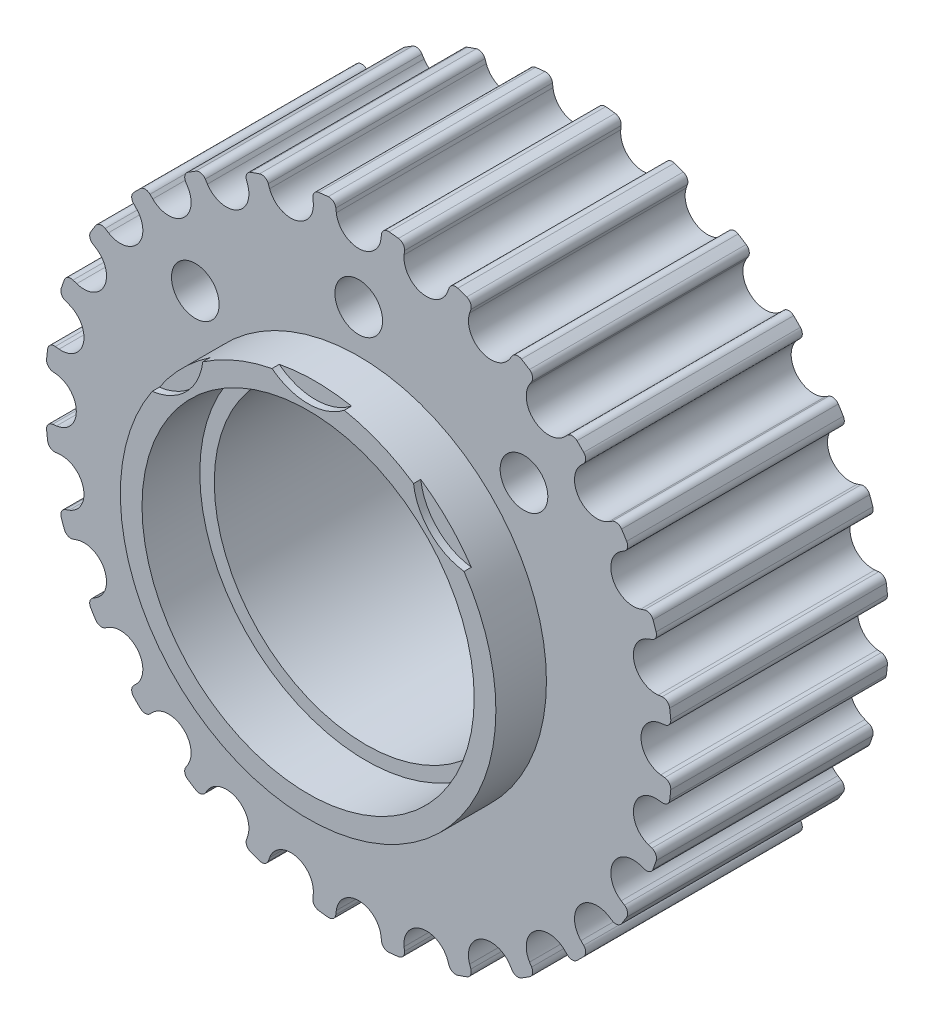
from build123d import *

# Parameters (mm, degrees)
SKETCH_2_R           = 10.5
EXTRUDE_1_DEPTH      = 15
SKETCH_12_R          = 13
SKETCH_12_R_2        = 11.5
EXTRUDE_2_DEPTH      = 3.5
EXTRUDE_2_DEPTH_BACK = 19.5
HOLE_WIZARD_M4_1_D   = 3.3
SKETCH_14_R          = 11.5
SKETCH_14_R_2        = 10.5
CUT_EXTRUDE_1_DEPTH  = 0.5
CUT_EXTRUDE_START    = 3.5
SKETCH_15_R          = 4.05
CUT_EXTRUDE_2_DEPTH  = 0.5
CUT_EXTRUDE_START_2  = -19.5
SKETCH_15_2_R        = 4.05
CUT_EXTRUDE_3_DEPTH  = 1.5
SKETCH_16_R          = 11.5
SKETCH_16_R_2        = 10.5
EXTRUDE_3_DEPTH      = 0.5


with BuildPart() as part:
    # 草图2 → 凸台-拉伸1 (new body)
    with BuildSketch(Plane.XY):
        with BuildLine():
            Line((1.331903556, 20.780403486), (1.298918642, 20.511762921))
            ThreePointArc((1.298918642, 20.511762921), (-0.249453355, 19.141879097), (-1.797825351, 20.511762921))
            Line((-1.797825351, 20.511762921), (-1.830810265, 20.780403486))
            ThreePointArc((-1.830810265, 20.780403486), (-2.006994407, 21.096415396), (-2.353762187, 21.19964565))
            ThreePointArc((-2.353762187, 21.19964565), (-2.679978202, 21.165383749), (-3.00563929, 21.12619674))
            ThreePointArc((-3.00563929, 21.12619674), (-3.320741986, 20.948391594), (-3.422189558, 20.601098103))
            Line((-3.422189558, 20.601098103), (-3.394569322, 20.331853084))
            ThreePointArc((-3.394569322, 20.331853084), (-4.599292572, 18.651769924), (-6.413671477, 19.642762718))
            Line((-6.413671477, 19.642762718), (-6.50560754, 19.897328069))
            ThreePointArc((-6.50560754, 19.897328069), (-6.747693643, 20.166212241), (-7.108738124, 20.189691206))
            ThreePointArc((-7.108738124, 20.189691206), (-7.419151232, 20.083698431), (-7.727927386, 19.973027513))
            ThreePointArc((-7.727927386, 19.973027513), (-7.995564432, 19.729563367), (-8.01718843, 19.36840304))
            Line((-8.01718843, 19.36840304), (-7.930348038, 19.112054636))
            ThreePointArc((-7.930348038, 19.112054636), (-8.731012687, 17.206018527), (-10.720417968, 17.768427773))
            Line((-10.720417968, 17.768427773), (-10.866695121, 17.996152941))
            ThreePointArc((-10.866695121, 17.996152941), (-11.162543977, 18.2044264), (-11.51976088, 18.146976743))
            ThreePointArc((-11.51976088, 18.146976743), (-11.798805672, 17.974568014), (-12.075213567, 17.797962688))
            ThreePointArc((-12.075213567, 17.797962688), (-12.281964525, 17.501047851), (-12.222680631, 17.144130775))
            Line((-12.222680631, 17.144130775), (-12.080974622, 16.913533367))
            ThreePointArc((-12.080974622, 16.913533367), (-12.437432001, 14.877120916), (-14.502106569, 14.982745068))
            Line((-14.502106569, 14.982745068), (-14.695389866, 15.172210962))
            ThreePointArc((-14.695389866, 15.172210962), (-15.030166378, 15.309430006), (-15.365643356, 15.173932493))
            ThreePointArc((-15.365643356, 15.173932493), (-15.599327361, 14.943753103), (-15.829506751, 14.710069098))
            ThreePointArc((-15.829506751, 14.710069098), (-15.965004264, 14.37459212), (-15.82778522, 14.039815608))
            Line((-15.82778522, 14.039815608), (-15.638319326, 13.846532311))
            ThreePointArc((-15.638319326, 13.846532311), (-15.532695174, 11.781857744), (-17.569107624, 11.425400364))
            Line((-17.569107624, 11.425400364), (-17.799705033, 11.567106373))
            ThreePointArc((-17.799705033, 11.567106373), (-18.156622109, 11.626390267), (-18.453536946, 11.41963931))
            ThreePointArc((-18.453536946, 11.41963931), (-18.630142271, 11.143231414), (-18.802551001, 10.864186622))
            ThreePointArc((-18.802551001, 10.864186622), (-18.860000658, 10.506969719), (-18.651727199, 10.211120863))
            Line((-18.651727199, 10.211120863), (-18.424002031, 10.06484371))
            ThreePointArc((-18.424002031, 10.06484371), (-17.861592784, 8.075438429), (-19.767628894, 7.27477378))
            Line((-19.767628894, 7.27477378), (-20.023977298, 7.361614172))
            ThreePointArc((-20.023977298, 7.361614172), (-20.385137624, 7.339990175), (-20.628601771, 7.072353128))
            ThreePointArc((-20.628601771, 7.072353128), (-20.739272689, 6.763576974), (-20.845265464, 6.453163866))
            ThreePointArc((-20.845265464, 6.453163866), (-20.821786499, 6.092119385), (-20.552902327, 5.850033282))
            Line((-20.552902327, 5.850033282), (-20.298336976, 5.75809722))
            ThreePointArc((-20.298336976, 5.75809722), (-19.307344182, 3.943718314), (-20.987427341, 2.738995064))
            Line((-20.987427341, 2.738995064), (-21.25667236, 2.7666153))
            ThreePointArc((-21.25667236, 2.7666153), (-21.603965852, 2.665167728), (-21.781770998, 2.350065032))
            ThreePointArc((-21.781770998, 2.350065032), (-21.820958007, 2.024403944), (-21.855219907, 1.69818793))
            ThreePointArc((-21.855219907, 1.69818793), (-21.751989654, 1.351420149), (-21.435977744, 1.175236007))
            Line((-21.435977744, 1.175236007), (-21.167337179, 1.142251093))
            ThreePointArc((-21.167337179, 1.142251093), (-19.797453355, -0.406120903), (-21.167337179, -1.9544929))
            Line((-21.167337179, -1.9544929), (-21.435977744, -1.987477814))
            ThreePointArc((-21.435977744, -1.987477814), (-21.751989654, -2.163661955), (-21.855219907, -2.510429736))
            ThreePointArc((-21.855219907, -2.510429736), (-21.820958007, -2.83664575), (-21.781770998, -3.162306838))
            ThreePointArc((-21.781770998, -3.162306838), (-21.603965852, -3.477409534), (-21.25667236, -3.578857107))
            Line((-21.25667236, -3.578857107), (-20.987427341, -3.55123687))
            ThreePointArc((-20.987427341, -3.55123687), (-19.307344182, -4.75596012), (-20.298336976, -6.570339026))
            Line((-20.298336976, -6.570339026), (-20.552902327, -6.662275089))
            ThreePointArc((-20.552902327, -6.662275089), (-20.821786499, -6.904361192), (-20.845265464, -7.265405672))
            ThreePointArc((-20.845265464, -7.265405672), (-20.739272689, -7.57581878), (-20.628601771, -7.884594935))
            ThreePointArc((-20.628601771, -7.884594935), (-20.385137624, -8.152231981), (-20.023977298, -8.173855979))
            Line((-20.023977298, -8.173855979), (-19.767628894, -8.087015586))
            ThreePointArc((-19.767628894, -8.087015586), (-17.861592784, -8.887680235), (-18.424002031, -10.877085516))
            Line((-18.424002031, -10.877085516), (-18.651727199, -11.023362669))
            ThreePointArc((-18.651727199, -11.023362669), (-18.860000658, -11.319211525), (-18.802551001, -11.676428428))
            ThreePointArc((-18.802551001, -11.676428428), (-18.630142271, -11.95547322), (-18.453536946, -12.231881116))
            ThreePointArc((-18.453536946, -12.231881116), (-18.156622109, -12.438632073), (-17.799705033, -12.379348179))
            Line((-17.799705033, -12.379348179), (-17.569107624, -12.237642171))
            ThreePointArc((-17.569107624, -12.237642171), (-15.532695174, -12.59409955), (-15.638319326, -14.658774118))
            Line((-15.638319326, -14.658774118), (-15.82778522, -14.852057414))
            ThreePointArc((-15.82778522, -14.852057414), (-15.965004264, -15.186833926), (-15.829506751, -15.522310905))
            ThreePointArc((-15.829506751, -15.522310905), (-15.599327361, -15.755994909), (-15.365643356, -15.9861743))
            ThreePointArc((-15.365643356, -15.9861743), (-15.030166378, -16.121671812), (-14.695389866, -15.984452768))
            Line((-14.695389866, -15.984452768), (-14.502106569, -15.794986874))
            ThreePointArc((-14.502106569, -15.794986874), (-12.437432001, -15.689362722), (-12.080974622, -17.725775173))
            Line((-12.080974622, -17.725775173), (-12.222680631, -17.956372582))
            ThreePointArc((-12.222680631, -17.956372582), (-12.281964525, -18.313289657), (-12.075213567, -18.610204494))
            ThreePointArc((-12.075213567, -18.610204494), (-11.798805672, -18.78680982), (-11.51976088, -18.95921855))
            ThreePointArc((-11.51976088, -18.95921855), (-11.162543977, -19.016668206), (-10.866695121, -18.808394748))
            Line((-10.866695121, -18.808394748), (-10.720417968, -18.58066958))
            ThreePointArc((-10.720417968, -18.58066958), (-8.731012687, -18.018260333), (-7.930348038, -19.924296443))
            Line((-7.930348038, -19.924296443), (-8.01718843, -20.180644846))
            ThreePointArc((-8.01718843, -20.180644846), (-7.995564432, -20.541805173), (-7.727927386, -20.785269319))
            ThreePointArc((-7.727927386, -20.785269319), (-7.419151232, -20.895940238), (-7.108738124, -21.001933013))
            ThreePointArc((-7.108738124, -21.001933013), (-6.747693643, -20.978454047), (-6.50560754, -20.709569876))
            Line((-6.50560754, -20.709569876), (-6.413671477, -20.455004524))
            ThreePointArc((-6.413671477, -20.455004524), (-4.599292572, -19.464011731), (-3.394569322, -21.14409489))
            Line((-3.394569322, -21.14409489), (-3.422189558, -21.413339909))
            ThreePointArc((-3.422189558, -21.413339909), (-3.320741986, -21.7606334), (-3.00563929, -21.938438546))
            ThreePointArc((-3.00563929, -21.938438546), (-2.679978202, -21.977625556), (-2.353762187, -22.011887456))
            ThreePointArc((-2.353762187, -22.011887456), (-2.006994407, -21.908657202), (-1.830810265, -21.592645292))
            Line((-1.830810265, -21.592645292), (-1.797825351, -21.324004727))
            ThreePointArc((-1.797825351, -21.324004727), (-0.249453355, -19.954120903), (1.298918642, -21.324004727))
            Line((1.298918642, -21.324004727), (1.331903556, -21.592645292))
            ThreePointArc((1.331903556, -21.592645292), (1.508087698, -21.908657202), (1.854855478, -22.011887456))
            ThreePointArc((1.854855478, -22.011887456), (2.181071493, -21.977625556), (2.506732581, -21.938438546))
            ThreePointArc((2.506732581, -21.938438546), (2.821835276, -21.7606334), (2.923282849, -21.413339909))
            Line((2.923282849, -21.413339909), (2.895662612, -21.14409489))
            ThreePointArc((2.895662612, -21.14409489), (4.100385862, -19.464011731), (5.914764768, -20.455004524))
            Line((5.914764768, -20.455004524), (6.006700831, -20.709569876))
            ThreePointArc((6.006700831, -20.709569876), (6.248786934, -20.978454047), (6.609831415, -21.001933013))
            ThreePointArc((6.609831415, -21.001933013), (6.920244522, -20.895940238), (7.229020677, -20.785269319))
            ThreePointArc((7.229020677, -20.785269319), (7.496657723, -20.541805173), (7.518281721, -20.180644846))
            Line((7.518281721, -20.180644846), (7.431441329, -19.924296443))
            ThreePointArc((7.431441329, -19.924296443), (8.232105978, -18.018260333), (10.221511258, -18.58066958))
            Line((10.221511258, -18.58066958), (10.367788412, -18.808394748))
            ThreePointArc((10.367788412, -18.808394748), (10.663637267, -19.016668206), (11.020854171, -18.95921855))
            ThreePointArc((11.020854171, -18.95921855), (11.299898962, -18.78680982), (11.576306858, -18.610204494))
            ThreePointArc((11.576306858, -18.610204494), (11.783057816, -18.313289657), (11.723773921, -17.956372582))
            Line((11.723773921, -17.956372582), (11.582067913, -17.725775173))
            ThreePointArc((11.582067913, -17.725775173), (11.938525292, -15.689362722), (14.00319986, -15.794986874))
            Line((14.00319986, -15.794986874), (14.196483156, -15.984452768))
            ThreePointArc((14.196483156, -15.984452768), (14.531259668, -16.121671812), (14.866736647, -15.9861743))
            ThreePointArc((14.866736647, -15.9861743), (15.100420651, -15.755994909), (15.330600042, -15.522310905))
            ThreePointArc((15.330600042, -15.522310905), (15.466097554, -15.186833926), (15.32887851, -14.852057414))
            Line((15.32887851, -14.852057414), (15.139412616, -14.658774118))
            ThreePointArc((15.139412616, -14.658774118), (15.033788465, -12.59409955), (17.070200915, -12.237642171))
            Line((17.070200915, -12.237642171), (17.300798324, -12.379348179))
            ThreePointArc((17.300798324, -12.379348179), (17.657715399, -12.438632073), (17.954630236, -12.231881116))
            ThreePointArc((17.954630236, -12.231881116), (18.131235562, -11.95547322), (18.303644292, -11.676428428))
            ThreePointArc((18.303644292, -11.676428428), (18.361093948, -11.319211525), (18.15282049, -11.023362669))
            Line((18.15282049, -11.023362669), (17.925095322, -10.877085516))
            ThreePointArc((17.925095322, -10.877085516), (17.362686075, -8.887680235), (19.268722185, -8.087015586))
            Line((19.268722185, -8.087015586), (19.525070588, -8.173855979))
            ThreePointArc((19.525070588, -8.173855979), (19.886230915, -8.152231981), (20.129695061, -7.884594935))
            ThreePointArc((20.129695061, -7.884594935), (20.24036598, -7.57581878), (20.346358755, -7.265405672))
            ThreePointArc((20.346358755, -7.265405672), (20.32287979, -6.904361192), (20.053995618, -6.662275089))
            Line((20.053995618, -6.662275089), (19.799430267, -6.570339026))
            ThreePointArc((19.799430267, -6.570339026), (18.808437473, -4.75596012), (20.488520632, -3.55123687))
            Line((20.488520632, -3.55123687), (20.757765651, -3.578857107))
            ThreePointArc((20.757765651, -3.578857107), (21.105059142, -3.477409534), (21.282864289, -3.162306838))
            ThreePointArc((21.282864289, -3.162306838), (21.322051298, -2.83664575), (21.356313198, -2.510429736))
            ThreePointArc((21.356313198, -2.510429736), (21.253082944, -2.163661955), (20.937071035, -1.987477814))
            Line((20.937071035, -1.987477814), (20.66843047, -1.9544929))
            ThreePointArc((20.66843047, -1.9544929), (19.298546645, -0.406120903), (20.66843047, 1.142251093))
            Line((20.66843047, 1.142251093), (20.937071035, 1.175236007))
            ThreePointArc((20.937071035, 1.175236007), (21.253082944, 1.351420149), (21.356313198, 1.69818793))
            ThreePointArc((21.356313198, 1.69818793), (21.322051298, 2.024403944), (21.282864289, 2.350065032))
            ThreePointArc((21.282864289, 2.350065032), (21.105059142, 2.665167728), (20.757765651, 2.7666153))
            Line((20.757765651, 2.7666153), (20.488520632, 2.738995064))
            ThreePointArc((20.488520632, 2.738995064), (18.808437473, 3.943718314), (19.799430267, 5.75809722))
            Line((19.799430267, 5.75809722), (20.053995618, 5.850033282))
            ThreePointArc((20.053995618, 5.850033282), (20.32287979, 6.092119385), (20.346358755, 6.453163866))
            ThreePointArc((20.346358755, 6.453163866), (20.24036598, 6.763576974), (20.129695061, 7.072353128))
            ThreePointArc((20.129695061, 7.072353128), (19.886230915, 7.339990175), (19.525070588, 7.361614172))
            Line((19.525070588, 7.361614172), (19.268722185, 7.27477378))
            ThreePointArc((19.268722185, 7.27477378), (17.362686075, 8.075438429), (17.925095322, 10.06484371))
            Line((17.925095322, 10.06484371), (18.15282049, 10.211120863))
            ThreePointArc((18.15282049, 10.211120863), (18.361093948, 10.506969719), (18.303644292, 10.864186622))
            ThreePointArc((18.303644292, 10.864186622), (18.131235562, 11.143231414), (17.954630236, 11.41963931))
            ThreePointArc((17.954630236, 11.41963931), (17.657715399, 11.626390267), (17.300798324, 11.567106373))
            Line((17.300798324, 11.567106373), (17.070200915, 11.425400364))
            ThreePointArc((17.070200915, 11.425400364), (15.033788465, 11.781857744), (15.139412616, 13.846532311))
            Line((15.139412616, 13.846532311), (15.32887851, 14.039815608))
            ThreePointArc((15.32887851, 14.039815608), (15.466097554, 14.37459212), (15.330600042, 14.710069098))
            ThreePointArc((15.330600042, 14.710069098), (15.100420651, 14.943753103), (14.866736647, 15.173932493))
            ThreePointArc((14.866736647, 15.173932493), (14.531259668, 15.309430006), (14.196483156, 15.172210962))
            Line((14.196483156, 15.172210962), (14.00319986, 14.982745068))
            ThreePointArc((14.00319986, 14.982745068), (11.938525292, 14.877120916), (11.582067913, 16.913533367))
            Line((11.582067913, 16.913533367), (11.723773921, 17.144130775))
            ThreePointArc((11.723773921, 17.144130775), (11.783057816, 17.501047851), (11.576306858, 17.797962688))
            ThreePointArc((11.576306858, 17.797962688), (11.299898962, 17.974568014), (11.020854171, 18.146976743))
            ThreePointArc((11.020854171, 18.146976743), (10.663637267, 18.2044264), (10.367788412, 17.996152941))
            Line((10.367788412, 17.996152941), (10.221511258, 17.768427773))
            ThreePointArc((10.221511258, 17.768427773), (8.232105978, 17.206018527), (7.431441329, 19.112054636))
            Line((7.431441329, 19.112054636), (7.518281721, 19.36840304))
            ThreePointArc((7.518281721, 19.36840304), (7.496657723, 19.729563367), (7.229020677, 19.973027513))
            ThreePointArc((7.229020677, 19.973027513), (6.920244522, 20.083698431), (6.609831415, 20.189691206))
            ThreePointArc((6.609831415, 20.189691206), (6.248786934, 20.166212241), (6.006700831, 19.897328069))
            Line((6.006700831, 19.897328069), (5.914764768, 19.642762718))
            ThreePointArc((5.914764768, 19.642762718), (4.100385862, 18.651769924), (2.895662612, 20.331853084))
            Line((2.895662612, 20.331853084), (2.923282849, 20.601098103))
            ThreePointArc((2.923282849, 20.601098103), (2.821835276, 20.948391594), (2.506732581, 21.12619674))
            ThreePointArc((2.506732581, 21.12619674), (2.181071493, 21.165383749), (1.854855478, 21.19964565))
            ThreePointArc((1.854855478, 21.19964565), (1.508087698, 21.096415396), (1.331903556, 20.780403486))
        make_face()
        with Locations((-0.245789015, -0.367741944)):
            Circle(SKETCH_2_R, mode=Mode.SUBTRACT)
    extrude(amount=EXTRUDE_1_DEPTH)


with BuildPart() as part_1:
    # Move Body 1: moved
    add(part.part.moved(Location((-21.775119277, 0, 0))))

    # 草图12 → 凸台-拉伸2 (add, two sides)
    with BuildSketch(Plane.XY.offset(15)) as extrude_2_sk:
        with Locations((-22.024572632, -0.309578045)):
            Circle(SKETCH_12_R)
        with Locations((-22.024572632, -0.309578045)):
            Circle(SKETCH_12_R_2, mode=Mode.SUBTRACT)
    extrude(amount=EXTRUDE_2_DEPTH)
    extrude(extrude_2_sk.sketch, amount=-EXTRUDE_2_DEPTH_BACK)

    # M4 螺纹孔1 (through all)
    with Locations(Plane(origin=(-33.334616791, 10.945966555, 15), x_dir=(1, 0, 0), z_dir=(0, 0, 1))):
        with Locations((0, 0), (11.313708499, 4.686291501), (22.755337645, -0.129383643)):
            Hole(HOLE_WIZARD_M4_1_D / 2)

    # 草图14 → 切除-拉伸1 (cut)
    with BuildSketch(Plane.XY.offset(15)):
        with Locations((-22.024572632, -0.309578045)):
            Circle(SKETCH_14_R)
        with Locations((-22.020908292, -0.367741944)):
            Circle(SKETCH_14_R_2, mode=Mode.SUBTRACT)
    extrude(amount=-CUT_EXTRUDE_1_DEPTH, mode=Mode.SUBTRACT)

    # 草图15 → 切除-拉伸2 (cut)
    with BuildSketch(Plane.XY.offset(15).offset(CUT_EXTRUDE_START)):
        with Locations((-22.020908292, 15.632258056)):
            Circle(SKETCH_15_R)
        with Locations((-10.707199793, 10.945966555)):
            Circle(SKETCH_15_R)
        with Locations((-33.334616791, 10.945966555)):
            Circle(SKETCH_15_R)
    extrude(amount=-CUT_EXTRUDE_2_DEPTH, mode=Mode.SUBTRACT)

    # 草图15<2> → 切除-拉伸3 (cut)
    with BuildSketch(Plane.XY.offset(15).offset(CUT_EXTRUDE_START_2)):
        with Locations((-22.020908292, 15.632258056)):
            Circle(SKETCH_15_2_R)
        with Locations((-10.707199793, 10.945966555)):
            Circle(SKETCH_15_2_R)
        with Locations((-33.334616791, 10.945966555)):
            Circle(SKETCH_15_2_R)
    extrude(amount=CUT_EXTRUDE_3_DEPTH, mode=Mode.SUBTRACT)

    # 草图16 → 凸台-拉伸3 (add)
    with BuildSketch(Plane(origin=(0, 0, 0), x_dir=(-1, 0, 0), z_dir=(0, 0, -1))):
        with Locations((22.024572632, -0.309578045)):
            Circle(SKETCH_16_R)
        with Locations((22.020908292, -0.367741944)):
            Circle(SKETCH_16_R_2, mode=Mode.SUBTRACT)
    extrude(amount=EXTRUDE_3_DEPTH)


solid = part_1.part
